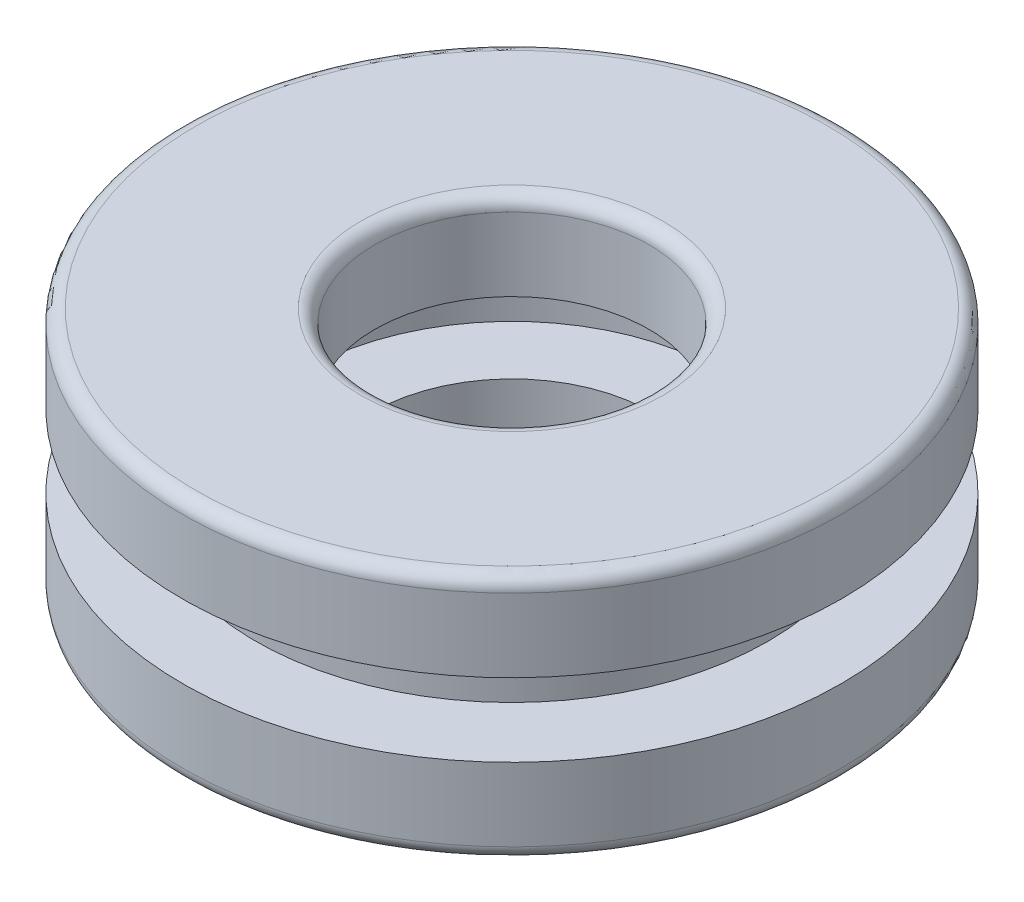
from build123d import *


with BuildPart() as part:
    # Эскиз1 → Повернуть1 (revolve)
    with BuildSketch(Plane.XY):
        with BuildLine():
            Line((5.1, 3.166666667), (7.666666667, 3.166666667))
            Line((7.666666667, 3.166666667), (7.666666667, 5.833333333))
            Line((7.666666667, 5.833333333), (5, 5.833333333))
            Line((5, 5.833333333), (5, 8.5))
            ThreePointArc((5, 8.5), (5.146446609, 8.853553391), (5.5, 9))
            Line((5.5, 9), (11.5, 9))
            ThreePointArc((11.5, 9), (11.853553391, 8.853553391), (12, 8.5))
            Line((12, 8.5), (12, 5.833333333))
            Line((12, 5.833333333), (9.333333333, 5.833333333))
            Line((9.333333333, 5.833333333), (9.333333333, 3.166666667))
            Line((9.333333333, 3.166666667), (12, 3.166666667))
            Line((12, 3.166666667), (12, 0.5))
            ThreePointArc((12, 0.5), (11.853553391, 0.146446609), (11.5, 0))
            Line((11.5, 0), (5.6, 0))
            ThreePointArc((5.6, 0), (5.246446609, 0.146446609), (5.1, 0.5))
            Line((5.1, 0.5), (5.1, 3.166666667))
        make_face()
    revolve(axis=Axis((0, -1000, 0), (0, 1, 0)))


solid = part.part
